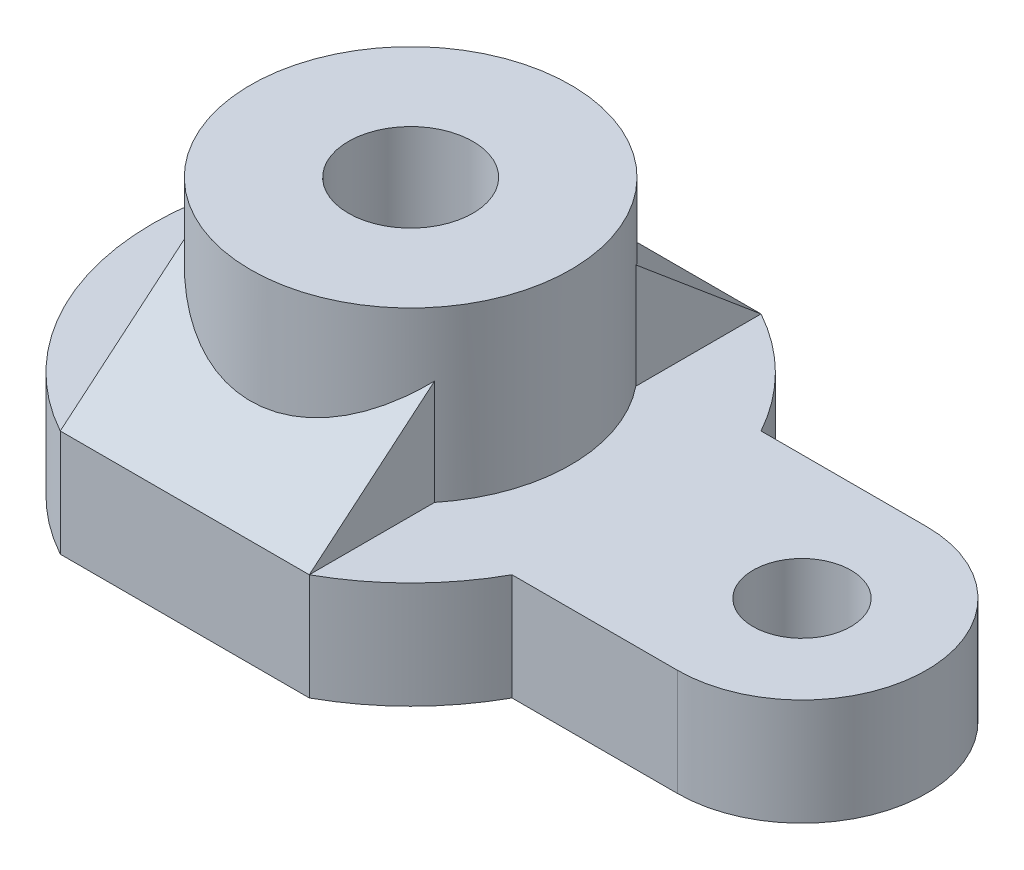
from build123d import *

# Parameters (mm, degrees)
SKETCH1_R          = 11
BASE_DEPTH         = 24
SKETCH2_R          = 36
SKETCH2_R_2        = 14
TOP_CYLINDER_DEPTH = 38
SIDE_ARMS_DEPTH    = 56


with BuildPart() as part:
    # Sketch1 → base (new body)
    with BuildSketch(Plane(origin=(0, 0, 0), x_dir=(1, 0, 0), z_dir=(0, 1, 0))):
        with BuildLine():
            Line((-28, -50.793700397), (28, -50.793700397))
            ThreePointArc((28, -50.793700397), (41.012193309, -41.012193309), (50.793700397, -28))
            Line((50.793700397, -28), (88, -28))
            ThreePointArc((88, -28), (116, 0), (88, 28))
            Line((88, 28), (50.793700397, 28))
            ThreePointArc((50.793700397, 28), (41.012193309, 41.012193309), (28, 50.793700397))
            Line((28, 50.793700397), (-28, 50.793700397))
            ThreePointArc((-28, 50.793700397), (-58, 0), (-28, -50.793700397))
        make_face()
        with Locations(Location((88, 0, 0), (0, 0, 270))):
            Circle(SKETCH1_R, mode=Mode.SUBTRACT)
    extrude(amount=BASE_DEPTH)

    # Sketch2 → top cylinder (add)
    with BuildSketch(Plane(origin=(0, 24, 0), x_dir=(1, 0, 0), z_dir=(0, 1, 0))):
        with Locations(Location((0, 0, 0), (0, 0, 270))):
            Circle(SKETCH2_R)
        with Locations(Location((0, 0, 0), (0, 0, 270))):
            Circle(SKETCH2_R_2, mode=Mode.SUBTRACT)
    extrude(amount=TOP_CYLINDER_DEPTH)

    # 3DSketch1 → side arms (add)
    with BuildSketch(Plane(origin=(28, 24, 50.793700397), x_dir=(0, 0, -1), z_dir=(1, 0, 0))):
        Polygon((0, 0), (28.166283399, 23.634318012), (28.166283399, 0), align=None)
        Polygon((101.587400794, 0), (73.421117395, 23.634318012), (73.421117395, 0), align=None)
    extrude(amount=-SIDE_ARMS_DEPTH)


solid = part.part
